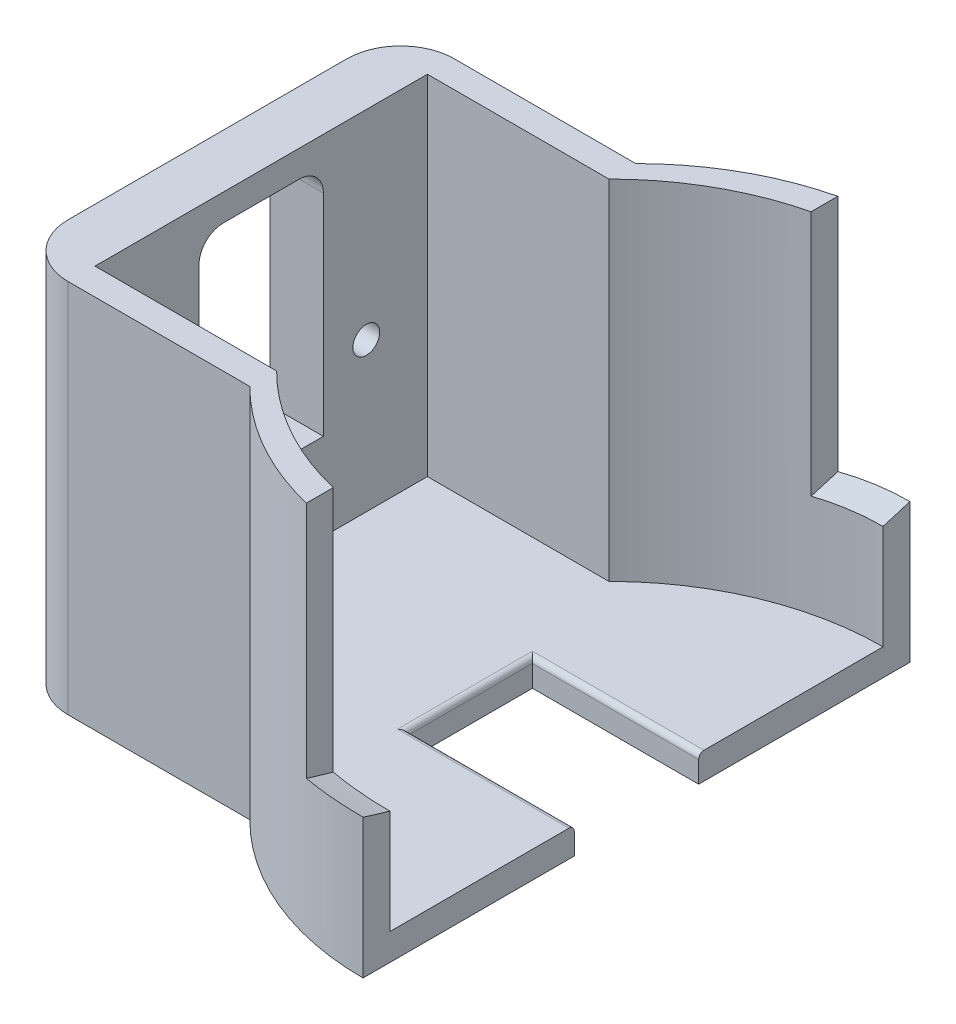
from build123d import *

# Parameters (mm, degrees)
BOSS_EXTRU_5_DEPTH       = 50
ESQUISSE5_R              = 2.15
ESQUISSE5_W              = 23.2
ESQUISSE5_H              = 31.8
ENL_V_MAT_EXTRU_1_DEPTH  = 10
BOSS_EXTRU_6_DEPTH       = 5
ESQUISSE9_W              = 102
ESQUISSE9_H              = 34.999999956
ENL_V_MAT_EXTRU_2_DEPTH  = 81
ESQUISSE11_R             = 2.5
ENL_V_MAT_EXTRU_9_DEPTH  = 5
ENL_V_MAT_EXTRU_12_DEPTH = 12
CONG_1_R                 = 10
ESQUISSE12_W             = 31
ESQUISSE12_H             = 23.2
ENL_V_MAT_EXTRU_13_DEPTH = 10
CONG_2_R                 = 1


with BuildPart() as part:
    # Esquisse1 → Boss.-Extru.5 (new body, symmetric)
    with BuildSketch(Plane(origin=(0, 0, 0), x_dir=(1, 0, 0), z_dir=(0, 1, 0))):
        with BuildLine():
            ThreePointArc((-36.124783736, -31), (-19.557607216, -42.100955404), (0, -46))
            Line((0, -46), (0, -51))
            ThreePointArc((0, -51), (-19.557607216, -47.100955404), (-36.124783736, -36))
            Line((-36.124783736, -36), (-80, -36))
            Line((-80, -36), (-80, 36))
            Line((-80, 36), (-36.124783736, 36))
            ThreePointArc((-36.124783736, 36), (-19.557607216, 47.100955404), (0, 51))
            Line((0, 51), (0, 46))
            ThreePointArc((0, 46), (-19.557607216, 42.100955404), (-36.124783736, 31))
            Line((-36.124783736, 31), (-70, 31))
            Line((-70, 31), (-70, -31))
            Line((-70, -31), (-36.124783736, -31))
        make_face()
    extrude(amount=BOSS_EXTRU_5_DEPTH, both=True)

    # Esquisse5 → Enlèv. mat.-Extru.1 (cut)
    with BuildSketch(Plane(origin=(-70, 0, 0), x_dir=(0, 0, -1), z_dir=(1, 0, 0))):
        with BuildLine():
            Line((-11.59999996, -2), (11.60000004, -2))
            Line((11.60000004, -2), (11.60000004, 5.500000044))
            ThreePointArc((11.60000004, 5.500000044), (10.281980555, 8.68198056), (7.10000004, 10.000000044))
            Line((7.10000004, 10.000000044), (-7.099999871, 10.000000044))
            ThreePointArc((-7.099999871, 10.000000044), (-10.281980449, 8.681980534), (-11.59999996, 5.499999956))
            Line((-11.59999996, 5.499999956), (-11.59999996, -2))
        make_face()
        Circle(ESQUISSE5_R, mode=Mode.SUBTRACT)
        Circle(ESQUISSE5_R)
        with Locations((4e-08, -17.9)):
            Rectangle(ESQUISSE5_W, ESQUISSE5_H)
        with BuildLine():
            ThreePointArc((2.15, 0), (-1.209582286, 1.77747312), (-0.788986692, -2))
            Line((-0.788986692, -2), (0.788986692, -2))
            ThreePointArc((0.788986692, -2), (1.77747312, -1.209582286), (2.15, 0))
        make_face()
        with BuildLine():
            Line((0.788986692, -2), (-0.788986692, -2))
            ThreePointArc((-0.788986692, -2), (0, -2.15), (0.788986692, -2))
        make_face()
    extrude(amount=-ENL_V_MAT_EXTRU_1_DEPTH, mode=Mode.SUBTRACT)

    # Esquisse8 → Boss.-Extru.6 (add)
    with BuildSketch(Plane(origin=(0, -50, 0), x_dir=(1, 0, 0), z_dir=(0, 1, 0))):
        with BuildLine():
            Line((0, -51), (0, 51))
            ThreePointArc((0, 51), (-19.557607216, 47.100955404), (-36.124783736, 36))
            Line((-36.124783736, 36), (-80, 36))
            Line((-80, 36), (-80, -36))
            Line((-80, -36), (-36.124783736, -36))
            ThreePointArc((-36.124783736, -36), (-19.557607216, -47.100955404), (0, -51))
        make_face()
    extrude(amount=-BOSS_EXTRU_6_DEPTH)

    # Esquisse9 → Enlèv. mat.-Extru.2 (cut, through all)
    with BuildSketch(Plane(origin=(0, 0, 0), x_dir=(0, 0, -1), z_dir=(1, 0, 0))):
        with Locations((0, 32.500000022)):
            Rectangle(ESQUISSE9_W, ESQUISSE9_H)
    extrude(amount=-ENL_V_MAT_EXTRU_2_DEPTH, mode=Mode.SUBTRACT)

    # Esquisse11 → Enlèv. mat.-Extru.9 (cut)
    with BuildSketch(Plane(origin=(-70, 0, 0), x_dir=(0, 0, -1), z_dir=(1, 0, 0))):
        with Locations((-19.59999996, -22.213953621)):
            Circle(ESQUISSE11_R)
        with Locations((19.59999996, -22.213953621)):
            Circle(ESQUISSE11_R)
    extrude(amount=-ENL_V_MAT_EXTRU_9_DEPTH, mode=Mode.SUBTRACT)

    # Esquisse10 → Enlèv. mat.-Extru.12 (cut)
    with BuildSketch(Plane(origin=(0, 0, 0), x_dir=(0, 0, -1), z_dir=(1, 0, 0))):
        with BuildLine():
            Line((136.28713183, 33.486696785), (85.263165158, 65.69401727))
            ThreePointArc((85.263165158, 65.69401727), (69.088826466, 48.564130721), (49.552191154, 35.397425514))
            ThreePointArc((49.552191154, 35.397425514), (-14.729470129, 24.226140009), (-73.513371624, 52.534840476))
            ThreePointArc((-73.513371624, 52.534840476), (-79.660455319, 58.871393898), (-85.263165158, 65.69401727))
            Line((-85.263165158, 65.69401727), (-136.28713183, 33.486696785))
            ThreePointArc((-136.28713183, 33.486696785), (-98.721588704, -4.696131807), (-51, -29.022011055))
            Line((-51, -29.022011055), (-51, 15.000000044))
            Line((-51, 15.000000044), (-46, 15.000000044))
            Line((-46, 15.000000044), (-46, -30.539714713))
            ThreePointArc((-46, -30.539714713), (0, -37), (46, -30.539714713))
            Line((46, -30.539714713), (46, 15.000000044))
            Line((46, 15.000000044), (51, 15.000000044))
            Line((51, 15.000000044), (51, -29.022011055))
            ThreePointArc((51, -29.022011055), (98.721588704, -4.696131807), (136.28713183, 33.486696785))
        make_face()
        with BuildLine():
            ThreePointArc((-51, -29.022011055), (-48.505936298, -29.800419724), (-46, -30.539714713))
            Line((-46, -30.539714713), (-46, 15.000000044))
            Line((-46, 15.000000044), (-51, 15.000000044))
            Line((-51, 15.000000044), (-51, -29.022011055))
        make_face()
        with BuildLine():
            ThreePointArc((46, -30.539714713), (48.505936298, -29.800419724), (51, -29.022011055))
            Line((51, -29.022011055), (51, 15.000000044))
            Line((51, 15.000000044), (46, 15.000000044))
            Line((46, 15.000000044), (46, -30.539714713))
        make_face()
    extrude(amount=-ENL_V_MAT_EXTRU_12_DEPTH, mode=Mode.SUBTRACT)

    # Congé1
    cong_1_edges = [part.edges().sort_by_distance(p)[0] for p in [
        (-80, -19.999999978, 36),
        (-80, -19.999999978, -36),
    ]]
    fillet(cong_1_edges, radius=CONG_1_R)

    # Esquisse12 → Enlèv. mat.-Extru.13 (cut)
    with BuildSketch(Plane(origin=(0, -55, 0), x_dir=(-1, 0, 0), z_dir=(0, -1, 0))):
        with Locations((15.5, 0)):
            Rectangle(ESQUISSE12_W, ESQUISSE12_H)
    extrude(amount=-ENL_V_MAT_EXTRU_13_DEPTH, mode=Mode.SUBTRACT)

    # Congé2
    cong_2_edges = [part.edges().sort_by_distance(p)[0] for p in [
        (-15.5, -50, -11.6),
        (-31, -50, 0),
        (-15.5, -50, 11.6),
    ]]
    fillet(cong_2_edges, radius=CONG_2_R)


solid = part.part
